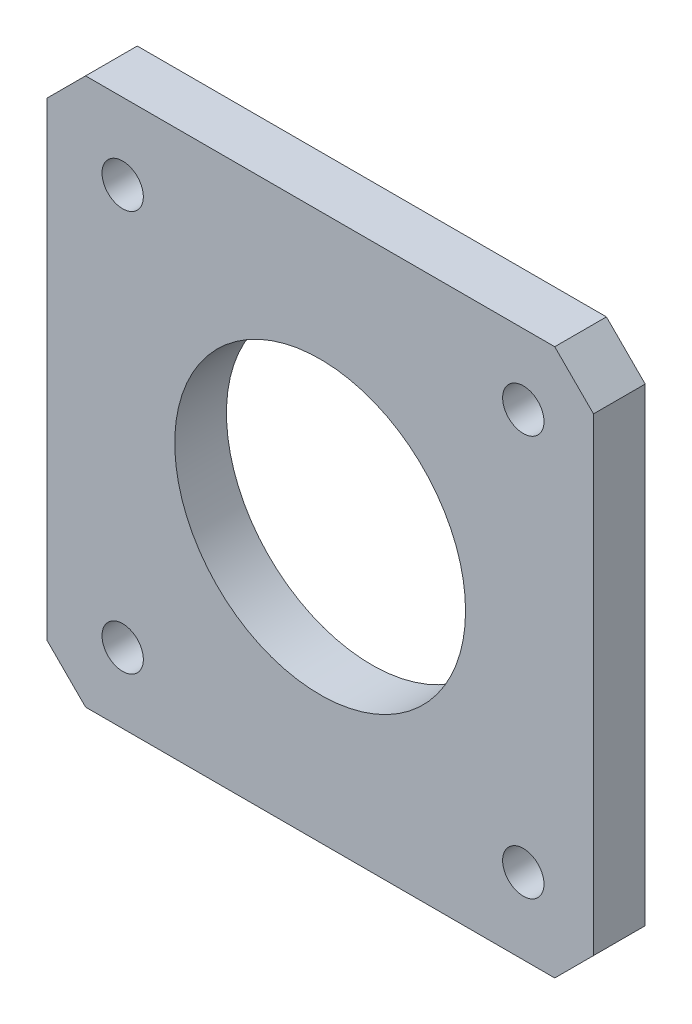
from build123d import *

# Parameters (mm, degrees)
SKETCH1_W           = 42.3
SKETCH1_H           = 42.3
SKETCH1_R           = 11.25
SKETCH1_R_2         = 1.6
BOSS_EXTRUDE1_DEPTH = 4
CHAMFER1_SIZE       = 3


with BuildPart() as part:
    # Sketch1 → Boss-Extrude1 (new body)
    with BuildSketch(Plane.XY):
        Rectangle(SKETCH1_W, SKETCH1_H)
        Circle(SKETCH1_R, mode=Mode.SUBTRACT)
        with Locations((15.717660824, 15.717660824)):
            Circle(SKETCH1_R_2, mode=Mode.SUBTRACT)
        with Locations((-15.279238797, 15.279238797)):
            Circle(SKETCH1_R_2, mode=Mode.SUBTRACT)
        with Locations((-15.279238797, -15.720761203)):
            Circle(SKETCH1_R_2, mode=Mode.SUBTRACT)
        with Locations((15.717660824, -15.282339176)):
            Circle(SKETCH1_R_2, mode=Mode.SUBTRACT)
    extrude(amount=BOSS_EXTRUDE1_DEPTH)

    # Chamfer1
    chamfer1_edges = [part.edges().sort_by_distance(p)[0] for p in [
        (21.15, -21.15, 2),
        (-21.15, -21.15, 2),
        (-21.15, 21.15, 2),
        (21.15, 21.15, 2),
    ]]
    chamfer(chamfer1_edges, length=CHAMFER1_SIZE)


solid = part.part
